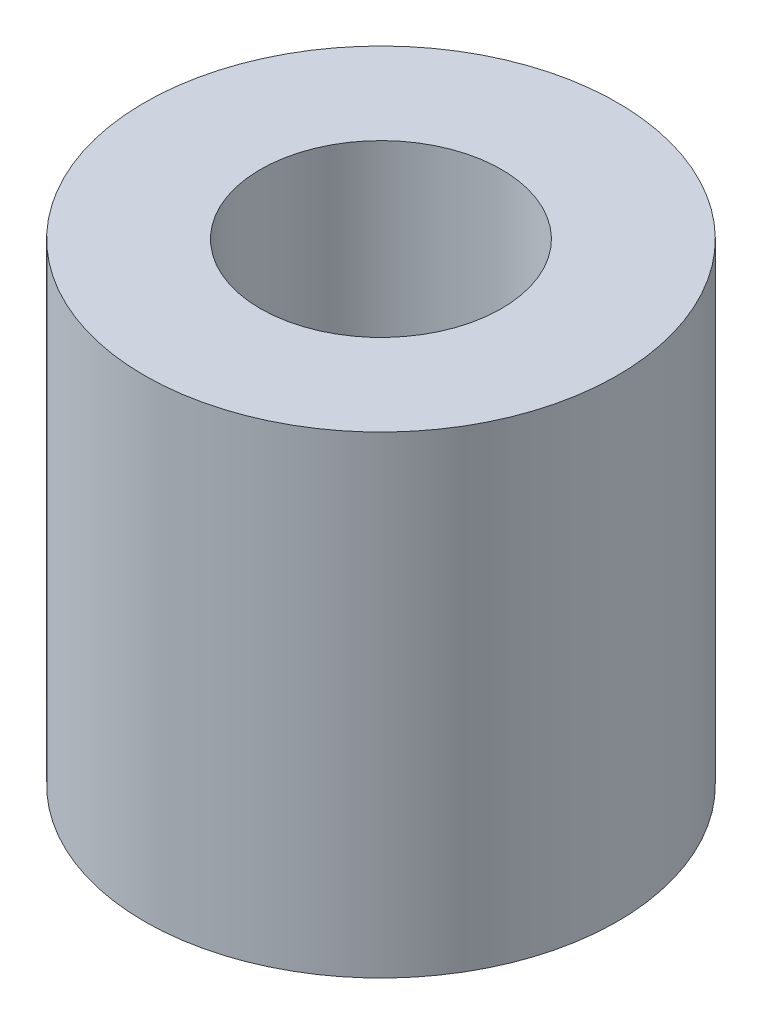
from build123d import *

# Parameters (mm, degrees)
SKETCH1_R           = 5
SKETCH1_R_2         = 2.55
BOSS_EXTRUDE1_DEPTH = 10


with BuildPart() as part:
    # Sketch1 → Boss-Extrude1 (new body)
    with BuildSketch(Plane(origin=(0, 0, 0), x_dir=(1, 0, 0), z_dir=(0, 1, 0))):
        Circle(SKETCH1_R)
        Circle(SKETCH1_R_2, mode=Mode.SUBTRACT)
    extrude(amount=BOSS_EXTRUDE1_DEPTH)


solid = part.part
